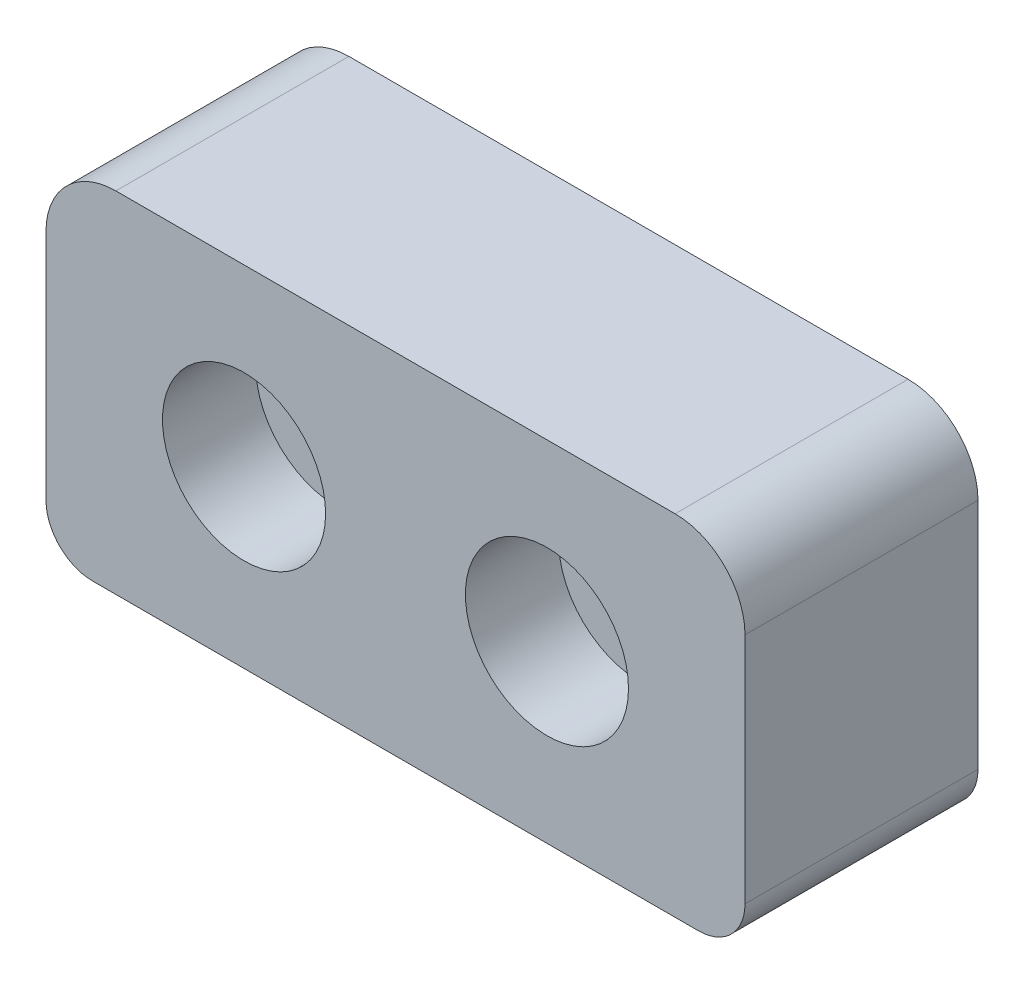
from build123d import *

# Parameters (mm, degrees)
EXTRUDE_1_DEPTH          = 10
FILLET_1_R               = 2
SKETCH_2_R               = 1.55
CUT_EXTRUDE_1_DEPTH      = 11
SKETCH_3_W               = 30
SKETCH_3_H               = 5
CUT_EXTRUDE_2_DEPTH      = 1
CUT_EXTRUDE_2_DEPTH_BACK = 11
FILLET_2_R               = 3
SKETCH_5_R               = 3.5
CUT_EXTRUDE_3_DEPTH      = 4


with BuildPart() as part:
    # 草图1 → 凸台-拉伸1 (new body)
    with BuildSketch(Plane.XY):
        Polygon((7.25, 0), (-7.25, 0), (-7.25, 5), (-15, 5), (-15, -15), (15, -15), (15, 5), (7.25, 5), align=None)
    extrude(amount=EXTRUDE_1_DEPTH)

    # 圆角1
    fillet_1_edges = [part.edges().sort_by_distance(p)[0] for p in [
        (15, 5, 5),
        (15, -15, 5),
        (-15, -15, 5),
        (-15, 5, 5),
    ]]
    fillet(fillet_1_edges, radius=FILLET_1_R)

    # 草图2 → 切除-拉伸1 (cut, through all)
    with BuildSketch(Plane.XY.offset(10)):
        with Locations((-6.5, -7.5)):
            Circle(SKETCH_2_R)
        with Locations((6.5, -7.5)):
            Circle(SKETCH_2_R)
    extrude(amount=-CUT_EXTRUDE_1_DEPTH, mode=Mode.SUBTRACT)

    # 草图3 → 切除-拉伸2 (cut, two sides)
    with BuildSketch(Plane.XY.offset(10)) as cut_extrude_2_sk:
        with Locations((0, 2.5)):
            Rectangle(SKETCH_3_W, SKETCH_3_H)
    extrude(amount=CUT_EXTRUDE_2_DEPTH, mode=Mode.SUBTRACT)
    extrude(cut_extrude_2_sk.sketch, amount=-CUT_EXTRUDE_2_DEPTH_BACK, mode=Mode.SUBTRACT)

    # 圆角2
    fillet_2_edges = [part.edges().sort_by_distance(p)[0] for p in [
        (15, 0, 5),
        (-15, 0, 5),
    ]]
    fillet(fillet_2_edges, radius=FILLET_2_R)

    # 草图5 → 切除-拉伸3 (cut)
    with BuildSketch(Plane.XY.offset(10)):
        with Locations((-6.5, -7.500000001)):
            Circle(SKETCH_5_R)
        with Locations((6.5, -7.5)):
            Circle(SKETCH_5_R)
    extrude(amount=-CUT_EXTRUDE_3_DEPTH, mode=Mode.SUBTRACT)


solid = part.part
